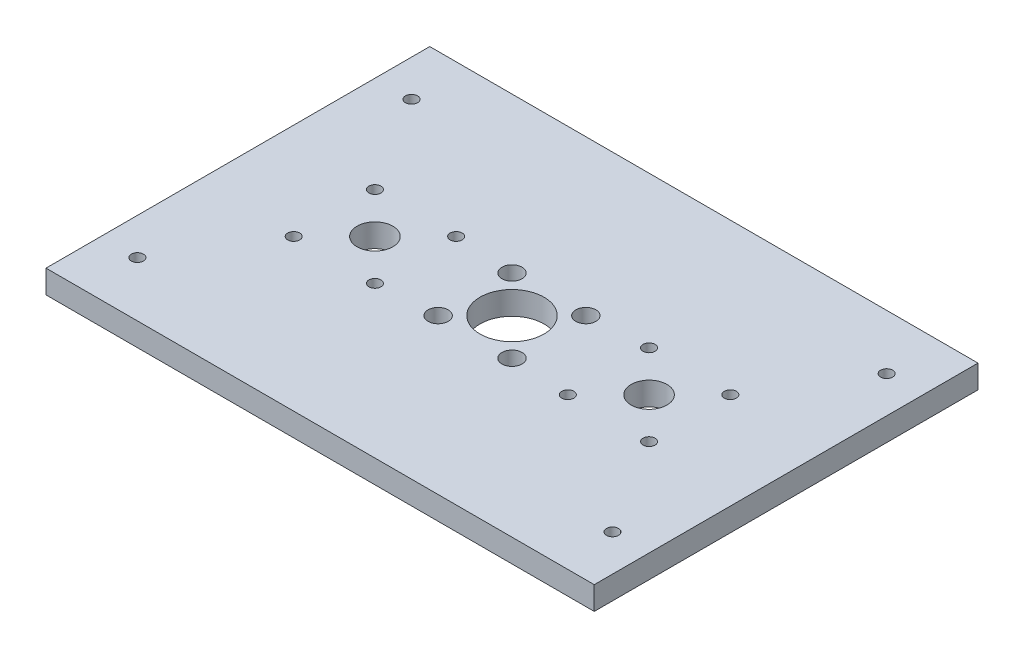
from build123d import *

# Parameters (mm, degrees)
SKETCH1_W            = 150
SKETCH1_H            = 105
SKETCH1_R            = 8.75
SKETCH1_R_2          = 2.75
BASE_DEPTH           = 6.35
SKETCH3_R            = 4.9
SKETCH3_R_2          = 1.65
BEARING_HOLES_DEPTH  = 7.35
SKETCH2_R            = 1.65
MOUNTING_HOLES_DEPTH = 7.35


with BuildPart() as part:
    # Sketch1 → Base (new body)
    with BuildSketch(Plane(origin=(0, 0, 0), x_dir=(1, 0, 0), z_dir=(0, 1, 0))):
        Rectangle(SKETCH1_W, SKETCH1_H)
        Circle(SKETCH1_R, mode=Mode.SUBTRACT)
        with Locations((10.102788136, 10.102788136)):
            Circle(SKETCH1_R_2, mode=Mode.SUBTRACT)
        with Locations((10.102788136, -10.102788136)):
            Circle(SKETCH1_R_2, mode=Mode.SUBTRACT)
        with Locations((-10.102788136, -10.102788136)):
            Circle(SKETCH1_R_2, mode=Mode.SUBTRACT)
        with Locations((-10.102788136, 10.102788136)):
            Circle(SKETCH1_R_2, mode=Mode.SUBTRACT)
    extrude(amount=BASE_DEPTH)

    # Sketch3 → Bearing Holes (cut, through all)
    with BuildSketch(Plane(origin=(0, 6.35, 0), x_dir=(1, 0, 0), z_dir=(0, 1, 0))):
        with Locations((37.5, 0)):
            Circle(SKETCH3_R)
        with Locations((26.3875, 11.1125)):
            Circle(SKETCH3_R_2)
        with Locations((48.6125, 11.1125)):
            Circle(SKETCH3_R_2)
        with Locations((48.6125, -11.1125)):
            Circle(SKETCH3_R_2)
        with Locations((26.3875, -11.1125)):
            Circle(SKETCH3_R_2)
        with Locations((-26.3875, -11.1125)):
            Circle(SKETCH3_R_2)
        with Locations((-48.6125, -11.1125)):
            Circle(SKETCH3_R_2)
        with Locations((-48.6125, 11.1125)):
            Circle(SKETCH3_R_2)
        with Locations((-26.3875, 11.1125)):
            Circle(SKETCH3_R_2)
        with Locations((-37.5, 0)):
            Circle(SKETCH3_R)
    extrude(amount=-BEARING_HOLES_DEPTH, mode=Mode.SUBTRACT)

    # Sketch2 → Mounting Holes (cut, through all)
    with BuildSketch(Plane(origin=(0, 6.35, 0), x_dir=(1, 0, 0), z_dir=(0, 1, 0))):
        with Locations((-65, 37.5)):
            Circle(SKETCH2_R)
        with Locations((-65, -37.5)):
            Circle(SKETCH2_R)
        with Locations((65, -37.5)):
            Circle(SKETCH2_R)
        with Locations((65, 37.5)):
            Circle(SKETCH2_R)
    extrude(amount=-MOUNTING_HOLES_DEPTH, mode=Mode.SUBTRACT)


solid = part.part
